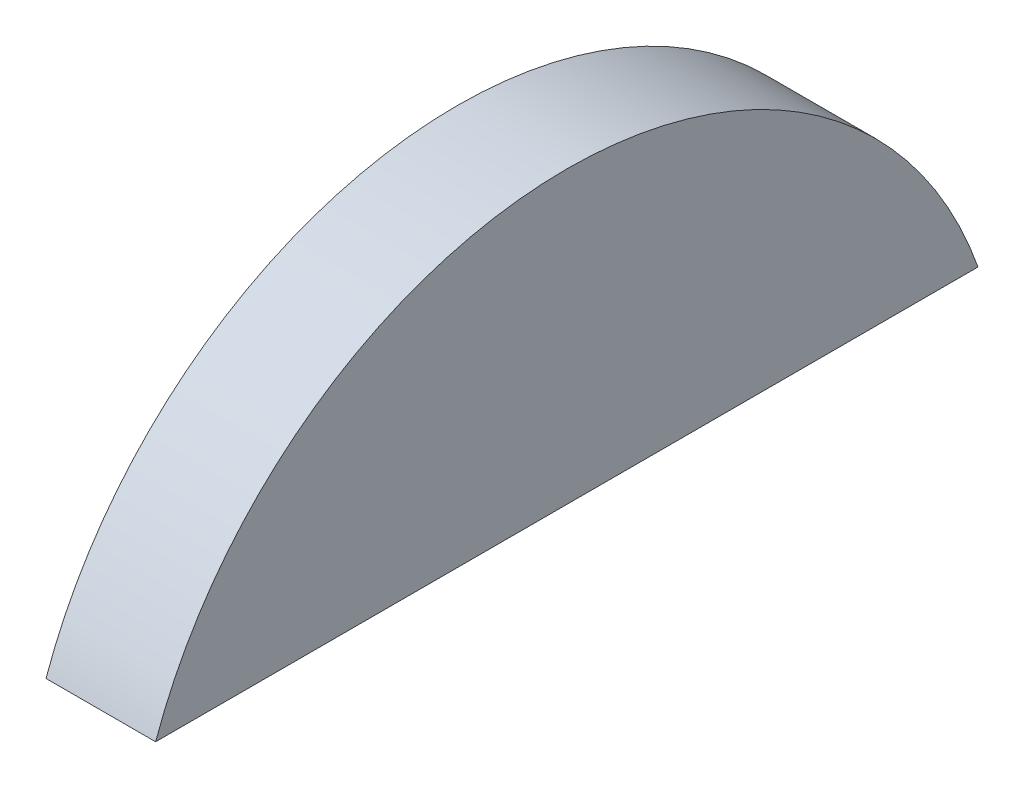
from build123d import *

# Parameters (mm, degrees)
BOSS_EXTRUDE2_DEPTH = 5.08


with BuildPart() as part:
    # Sketch2 → Boss-Extrude2 (new body)
    with BuildSketch(Plane(origin=(0, 0, 0), x_dir=(0, 0, -1), z_dir=(1, 0, 0))):
        with BuildLine():
            Line((-19.05, 6.747773585), (19.05, 6.747773585))
            ThreePointArc((19.05, 6.747773585), (0, 20.209773585), (-19.05, 6.747773585))
        make_face()
    extrude(amount=BOSS_EXTRUDE2_DEPTH)


solid = part.part
